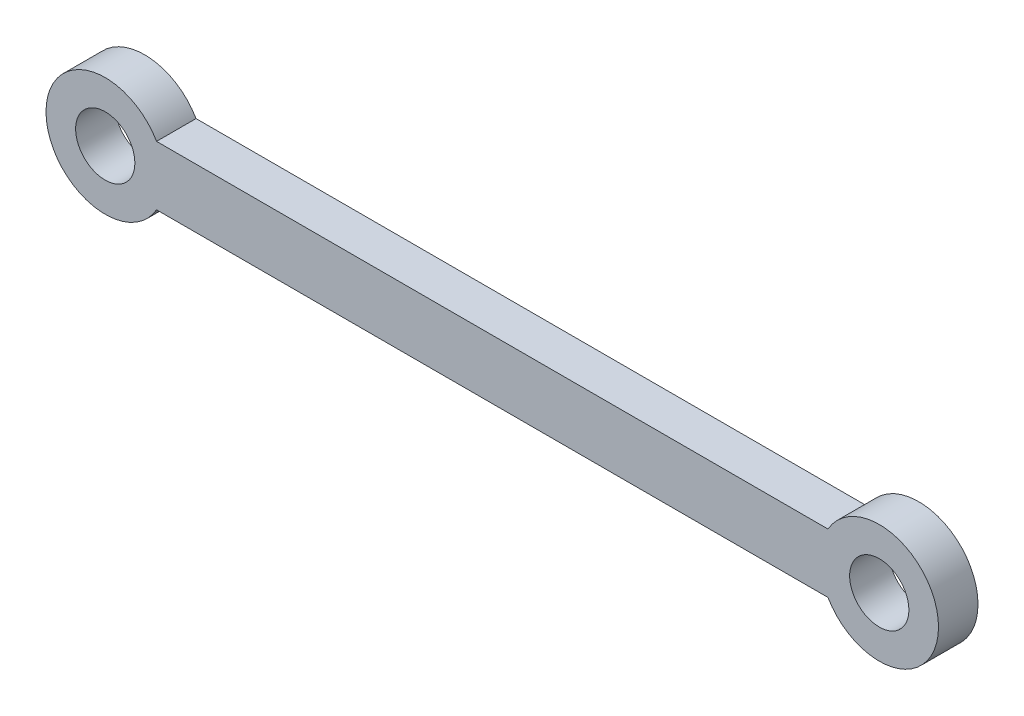
from build123d import *

# Parameters (mm, degrees)
SKETCH1_R           = 1.5
BOSS_EXTRUDE1_DEPTH = 2


with BuildPart() as part:
    # Sketch1 → Boss-Extrude1 (new body)
    with BuildSketch(Plane.XY):
        with BuildLine():
            Line((0, 0), (34, 0))
            ThreePointArc((34, 0), (39.598076211, 1.5), (34, 3))
            Line((34, 3), (0, 3))
            ThreePointArc((0, 3), (-5.598076211, 1.5), (0, 0))
        make_face()
        with Locations((36.598076211, 1.5)):
            Circle(SKETCH1_R, mode=Mode.SUBTRACT)
        with Locations((-2.598076211, 1.5)):
            Circle(SKETCH1_R, mode=Mode.SUBTRACT)
    extrude(amount=BOSS_EXTRUDE1_DEPTH)


solid = part.part
